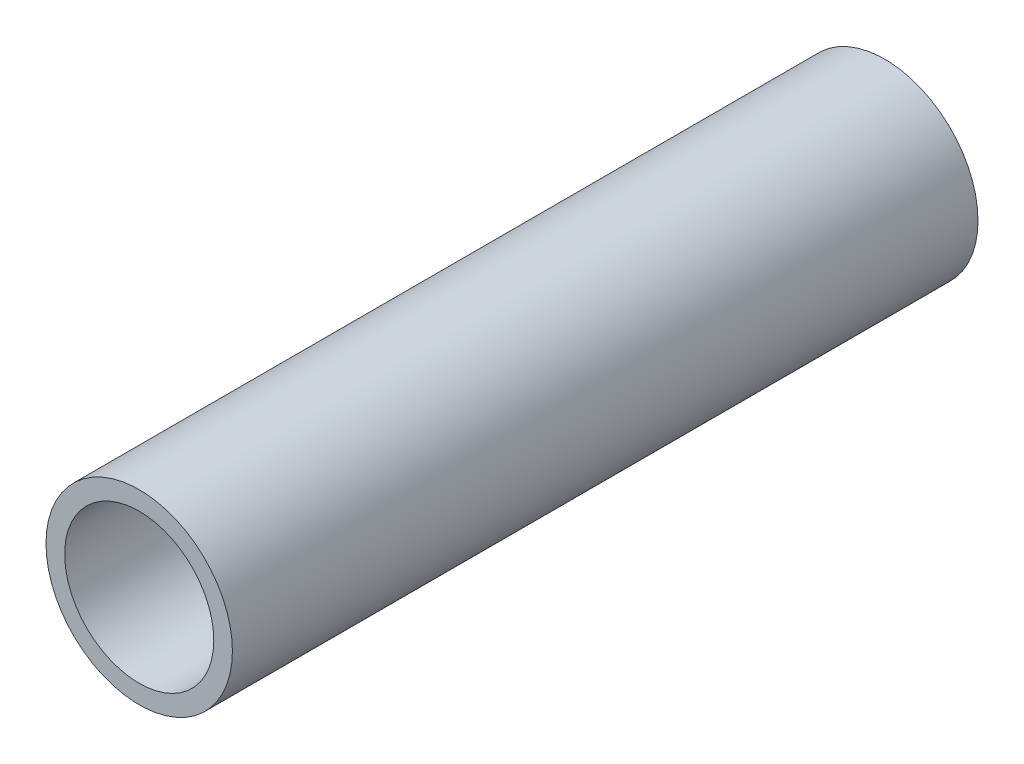
from build123d import *

# Parameters (mm, degrees)
SKETCH1_R           = 1.25
SKETCH1_R_2         = 1
BOSS_EXTRUDE1_DEPTH = 10


with BuildPart() as part:
    # Sketch1 → Boss-Extrude1 (new body)
    with BuildSketch(Plane.XY):
        Circle(SKETCH1_R)
        Circle(SKETCH1_R_2, mode=Mode.SUBTRACT)
    extrude(amount=BOSS_EXTRUDE1_DEPTH)


solid = part.part
